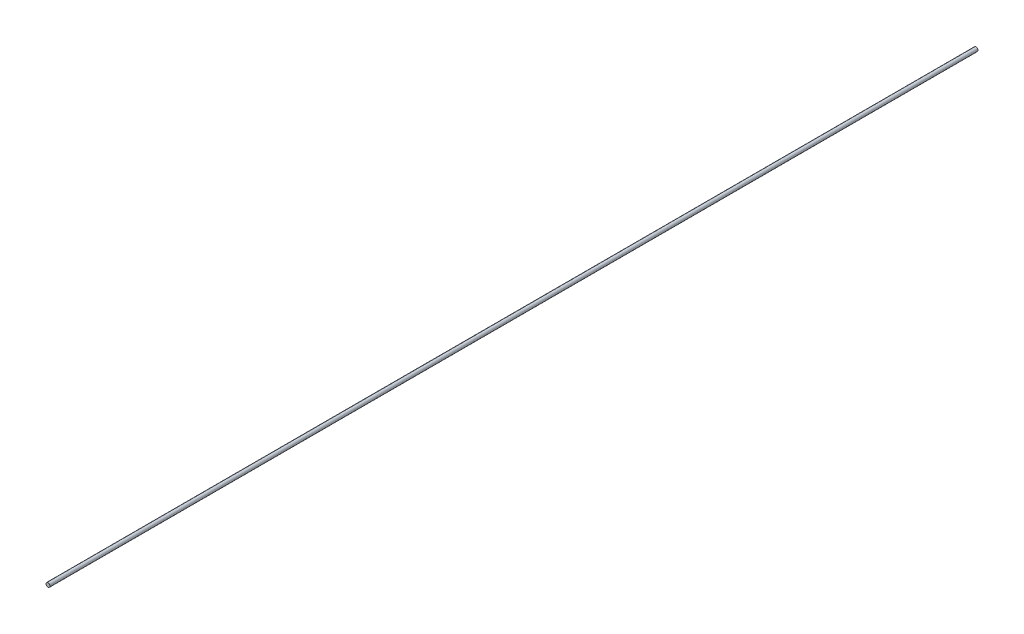
from build123d import *

# Parameters (mm, degrees)
SKETCH1_R           = 1.55
BOSS_EXTRUDE1_DEPTH = 360


with BuildPart() as part:
    # Sketch1 → Boss-Extrude1 (new body, symmetric)
    with BuildSketch(Plane.XY):
        Circle(SKETCH1_R)
    extrude(amount=BOSS_EXTRUDE1_DEPTH, both=True)


solid = part.part
